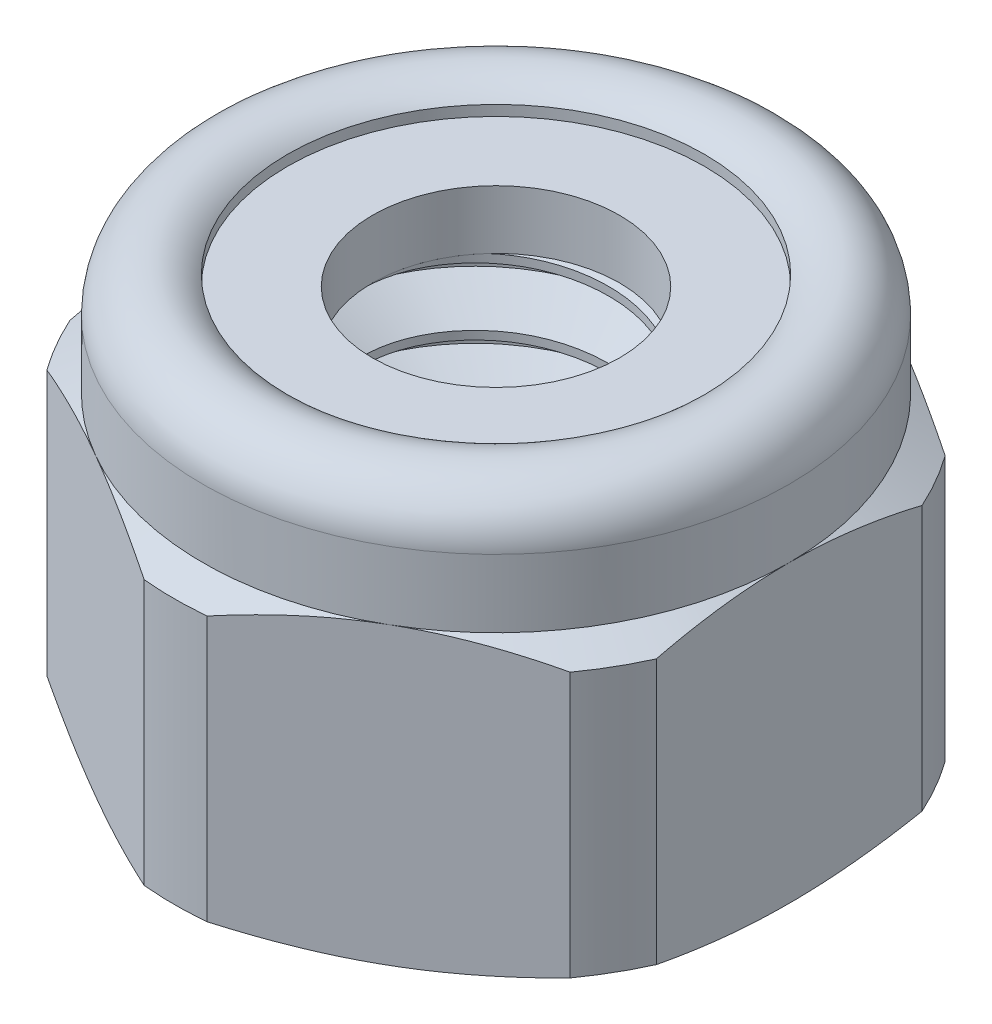
from build123d import *

# Parameters (mm, degrees)
SKETCH2_R                = 2.350110803
BOSS_EXTRUDE1_DEPTH      = 3.9751
BOSS_EXTRUDE1_DEPTH_BACK = 3.9751
SKETCH4_W                = 1.612594598
SKETCH4_H                = 1.114607508
SKETCH11_OUTSIDE_W       = 16.91
SKETCH11_OUTSIDE_H       = 18.636
SKETCH11_OUTSIDE_R       = 6.1214
CUT_EXTRUDE1_DEPTH       = 12.650534163
SKETCH6_W                = 3.175
SKETCH6_H                = 6.36016
CUT_SWEEP1_PITCH         = 1.27
CUT_SWEEP1_HEIGHT        = 7.9502
CUT_SWEEP1_RADIUS        = 3.175
CUT_SWEEP1_START_ANGLE   = 90
SKETCH10_R               = 2.985110803
BOSS_EXTRUDE2_DEPTH      = 6.36016


with BuildPart() as part:
    # Sketch2 → Boss-Extrude1 (new, two sides)
    with BuildSketch(Plane(origin=(0, 0, 0), x_dir=(1, 0, 0), z_dir=(0, 1, 0))) as boss_extrude1_sk:
        Polygon((0, 6.437801912), (-5.5753, 3.218900956), (-5.5753, -3.218900956), (0, -6.437801912), (5.5753, -3.218900956), (5.5753, 3.218900956), align=None)
        with Locations(Location((0, 0, 0), (0, 0, 270))):
            Circle(SKETCH2_R, mode=Mode.SUBTRACT)
    extrude(amount=BOSS_EXTRUDE1_DEPTH)
    extrude(boss_extrude1_sk.sketch, amount=-BOSS_EXTRUDE1_DEPTH_BACK)

    # Sketch3 → Cut-Revolve2 (revolve, cut)
    with BuildSketch(Plane(origin=(0, 0, 0), x_dir=(0, 0, -1), z_dir=(1, 0, 0)), mode=Mode.PRIVATE) as cut_revolve2_sk:
        with BuildLine():
            Line((6.437801912, 1.7399), (6.437801912, 4.9751))
            Line((6.437801912, 4.9751), (2.350110803, 4.9751))
            Line((2.350110803, 4.9751), (2.350110803, 2.38506))
            Line((2.350110803, 2.38506), (3.962705401, 2.38506))
            Line((3.962705401, 2.38506), (3.962705401, 3.698422508))
            ThreePointArc((3.962705401, 3.698422508), (4.992160519, 3.903193863), (5.5753, 3.030463955))
            Line((5.5753, 3.030463955), (5.5753, 1.7399))
            Line((5.5753, 1.7399), (6.437801912, 1.23371655))
            Line((6.437801912, 1.23371655), (6.437801912, 1.7399))
        make_face()
        Polygon((5.352288, -3.9751), (6.437801912, -3.46891655), (6.437801912, -3.9751), align=None)
        Polygon((2.350110803, -3.9751), (2.350110803, -3.3401), (2.985110803, -3.9751), align=None)
    revolve(cut_revolve2_sk.sketch.rotate(Axis((0, -3.9751, 0), (0, 1, 0)), 270), axis=Axis((0, -3.9751, 0), (0, 1, 0)), mode=Mode.SUBTRACT)

    # Sketch11 outside → Cut-Extrude1 (cut, through all)
    with BuildSketch(Plane.XZ.offset(3.9751)):
        Rectangle(SKETCH11_OUTSIDE_W, SKETCH11_OUTSIDE_H)
        Circle(SKETCH11_OUTSIDE_R, mode=Mode.SUBTRACT)
    extrude(amount=-CUT_EXTRUDE1_DEPTH, mode=Mode.SUBTRACT)

    # Sketch10 → Boss-Extrude2 (add)
    with BuildSketch(Plane.XZ.offset(3.9751)):
        Circle(SKETCH10_R)
    extrude(amount=-BOSS_EXTRUDE2_DEPTH)


with BuildPart() as body_2:
    # Sketch4 → Revolve1 (revolve)
    with BuildSketch(Plane(origin=(0, 0, 0), x_dir=(0, 0, -1), z_dir=(1, 0, 0)), mode=Mode.PRIVATE) as revolve1_sk:
        with Locations((-3.156408102, 2.942363754)):
            Rectangle(SKETCH4_W, SKETCH4_H)
    revolve(revolve1_sk.sketch.rotate(Axis((0, -3.9751, 0), (0, 1, 0)), 90), axis=Axis((0, -3.9751, 0), (0, 1, 0)))


with BuildPart() as body_3:
    # Sketch6 → Revolve2 (revolve)
    with BuildSketch(Plane.XY, mode=Mode.PRIVATE) as revolve2_sk:
        with Locations((1.5875, -0.79502)):
            Rectangle(SKETCH6_W, SKETCH6_H)
    revolve(revolve2_sk.sketch.rotate(Axis((0, -3.9751, 0), (0, 1, 0)), 90), axis=Axis((0, -3.9751, 0), (0, 1, 0)))

    # Cut-Sweep1: sweep along a helix
    with BuildLine() as cut_sweep1_path:
        add(Helix(CUT_SWEEP1_PITCH, CUT_SWEEP1_HEIGHT, CUT_SWEEP1_RADIUS, center=(0, -3.9751, 0), direction=(0, 1, 0), mode=Mode.PRIVATE).rotate(Axis((0, -3.9751, 0), (0, 1, 0)), CUT_SWEEP1_START_ANGLE))
    # Sketch8 → Cut-Sweep1 (sweep, cut)
    with BuildSketch(Plane.XY):
        Polygon((2.350110803, -4.45135), (2.350110803, -4.6101), (3.243740766, -5.1260375), (3.312481533, -3.895725), align=None)
    sweep(path=cut_sweep1_path.line, is_frenet=True, mode=Mode.SUBTRACT)

    # Sketch9 → Revolve3 (revolve)
    with BuildSketch(Plane.XY, mode=Mode.PRIVATE) as revolve3_sk:
        Polygon((0, -0.8001), (0, -3.9751), (3.175, -3.9751), (3.81, -3.9751), (0, -0.1651), align=None)
    revolve(revolve3_sk.sketch.rotate(Axis((0, -0.8001, 0), (0, -1, 0)), 180), axis=Axis((0, -0.8001, 0), (0, -1, 0)))


with BuildPart() as part_1:
    add(part.part)

    # Combine1: cut body 3
    add(body_3.part, mode=Mode.SUBTRACT)


solid = Compound([body_2.part, part_1.part])
